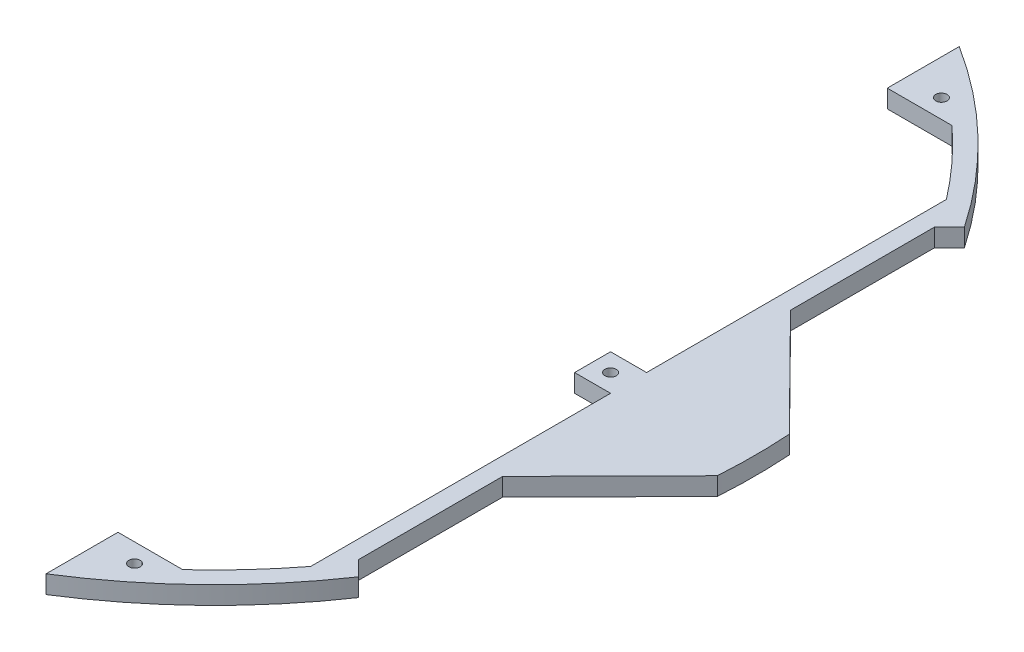
from build123d import *

# Parameters (mm, degrees)
BOSS_EXTRUDE2_DEPTH = 6.35
SKETCH40_R          = 2
CUT_EXTRUDE1_DEPTH  = 6.35
SKETCH41_R          = 2
CUT_EXTRUDE2_DEPTH  = 6.35


with BuildPart() as part:
    # Sketch1 → Boss-Extrude2 (new body)
    with BuildSketch(Plane(origin=(0, 0, 0), x_dir=(1, 0, 0), z_dir=(0, 1, 0))):
        with BuildLine():
            Line((152.4, -101.6), (152.4, -50.8))
            Line((152.4, -50.8), (190.076195248, -12.7))
            ThreePointArc((190.076195248, -12.7), (190.5, 0), (190.076195248, 12.7))
            Line((190.076195248, 12.7), (152.4, 50.8))
            Line((152.4, 50.8), (152.4, 101.6))
            Line((152.4, 101.6), (157.687433266, 106.887433266))
            ThreePointArc((157.687433266, 106.887433266), (155.08800922, 110.62531083), (152.4, 114.3))
            ThreePointArc((152.4, 114.3), (129.141828926, 140.045128518), (101.6, 161.144934764))
            Line((101.6, 161.144934764), (101.6, 135.744934764))
            Line((101.6, 135.744934764), (124.436872293, 135.744934764))
            ThreePointArc((124.436872293, 135.744934764), (135.756435031, 124.424325787), (146.05, 112.163363002))
            Line((146.05, 112.163363002), (146.05, 6.35))
            Line((146.05, 6.35), (133.35, 6.35))
            Line((133.35, 6.35), (133.35, -6.35))
            Line((133.35, -6.35), (146.05, -6.35))
            Line((146.05, -6.35), (146.05, -112.163363002))
            ThreePointArc((146.05, -112.163363002), (135.756435031, -124.424325787), (124.436872293, -135.744934764))
            Line((124.436872293, -135.744934764), (101.6, -135.744934764))
            Line((101.6, -135.744934764), (101.6, -161.144934764))
            ThreePointArc((101.6, -161.144934764), (129.141828926, -140.045128518), (152.4, -114.3))
            ThreePointArc((152.4, -114.3), (155.08800922, -110.62531083), (157.687433266, -106.887433266))
            Line((157.687433266, -106.887433266), (152.4, -101.6))
        make_face()
    extrude(amount=BOSS_EXTRUDE2_DEPTH)

    # Sketch40 → Cut-Extrude1 (cut)
    with BuildSketch(Plane(origin=(0, 6.35, 0), x_dir=(1, 0, 0), z_dir=(0, 1, 0))):
        with Locations((139.7, 0)):
            Circle(SKETCH40_R)
    extrude(amount=-CUT_EXTRUDE1_DEPTH, mode=Mode.SUBTRACT)

    # Sketch41 → Cut-Extrude2 (cut)
    with BuildSketch(Plane(origin=(0, 6.35, 0), x_dir=(1, 0, 0), z_dir=(0, 1, 0))):
        with Locations((114.080655546, 142.381475202)):
            Circle(SKETCH41_R)
        with Locations((114.080655546, -142.381475202)):
            Circle(SKETCH41_R)
    extrude(amount=-CUT_EXTRUDE2_DEPTH, mode=Mode.SUBTRACT)


solid = part.part
